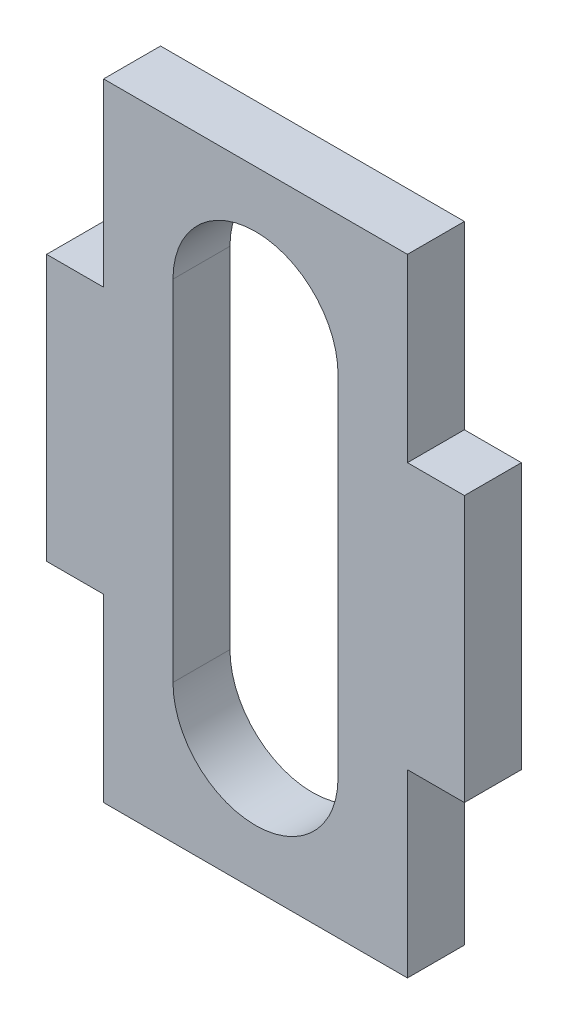
from build123d import *

# Parameters (mm, degrees)
SKETCH1_W           = 16
SKETCH1_H           = 33
BOSS_EXTRUDE1_DEPTH = 3
SKETCH2_W           = 22
SKETCH2_H           = 14
BOSS_EXTRUDE2_DEPTH = 3
CUT_EXTRUDE1_DEPTH  = 10


with BuildPart() as part:
    # Sketch1 → Boss-Extrude1 (new body)
    with BuildSketch(Plane.XY):
        Rectangle(SKETCH1_W, SKETCH1_H)
    extrude(amount=BOSS_EXTRUDE1_DEPTH)

    # Sketch2 → Boss-Extrude2 (add)
    with BuildSketch(Plane.XY.offset(3)):
        Rectangle(SKETCH2_W, SKETCH2_H)
    extrude(amount=-BOSS_EXTRUDE2_DEPTH)

    # Sketch3 → Cut-Extrude1 (cut)
    with BuildSketch(Plane.XY.offset(3)):
        with BuildLine():
            Line((4.345494921, 9.196065885), (4.345494921, -9.196065885))
            ThreePointArc((4.345494921, -9.196065885), (0, -13.541560806), (-4.345494921, -9.196065885))
            Line((-4.345494921, -9.196065885), (-4.345494921, 9.196065885))
            ThreePointArc((-4.345494921, 9.196065885), (0, 13.541560806), (4.345494921, 9.196065885))
        make_face()
    extrude(amount=-CUT_EXTRUDE1_DEPTH, mode=Mode.SUBTRACT)


solid = part.part
